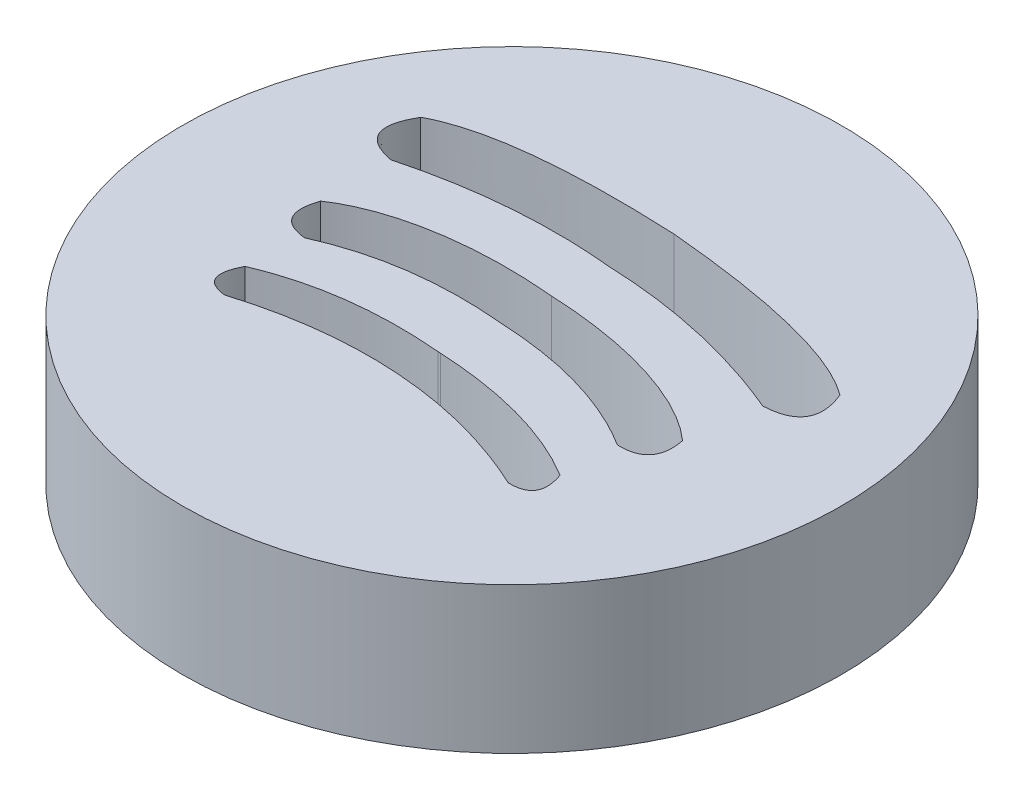
from build123d import *

# Parameters (mm, degrees)
SKETCH1_R           = 4.510832166
BOSS_EXTRUDE1_DEPTH = 2


with BuildPart() as part:
    # Sketch1 → Boss-Extrude1 (new body)
    with BuildSketch(Plane(origin=(0, 0, 0), x_dir=(1, 0, 0), z_dir=(0, 1, 0))):
        with Locations((4.847257792, 4.635414513)):
            Circle(SKETCH1_R)
        with BuildLine():
            Line((4.765839993, 3.704152946), (4.801053978, 3.701743172))
            add(Edge.make_bspline(
                [(4.801053978, 3.701743172), (6.14048774, 3.63517676), (7.067136471, 3.075228485)],
                knots=[0, 0, 0, 1, 1, 1], degree=2))
            add(Edge.make_bspline(
                [(7.067136471, 3.075228485), (7.229894904, 2.616221828), (6.804254242, 2.628959028)],
                knots=[0, 0, 0, 1, 1, 1], degree=2))
            add(Edge.make_bspline(
                [(6.804254242, 2.628959028), (5.8095543, 3.091031812), (4.77441326, 3.163396408)],
                knots=[0, 0, 0, 1, 1, 1], degree=2))
            Line((4.77441326, 3.163396408), (4.718895199, 3.167195635))
            add(Edge.make_bspline(
                [(2.635172404, 2.914258811), (3.683546068, 3.236519406), (4.718895199, 3.167195635)],
                knots=[0, 0, 0, 1, 1, 1], degree=2))
            add(Edge.make_bspline(
                [(2.43553462, 3.392179568), (2.211764545, 2.959623939), (2.635172404, 2.914258811)],
                knots=[0, 0, 0, 1, 1, 1], degree=2))
            add(Edge.make_bspline(
                [(4.765839993, 3.704152946), (3.429824714, 3.820673616), (2.43553462, 3.392179568)],
                knots=[0, 0, 0, 1, 1, 1], degree=2))
        make_face(mode=Mode.SUBTRACT)
        with BuildLine():
            Line((4.833097784, 4.473451505), (4.839222124, 4.473032403))
            add(Edge.make_bspline(
                [(7.101962805, 3.824170948), (6.157905723, 4.415694672), (4.839222124, 4.473032403)],
                knots=[0, 0, 0, 1, 1, 1], degree=2))
            add(Edge.make_bspline(
                [(7.496384151, 4.321712857), (7.596066747, 3.809653625), (7.101962805, 3.824170948)],
                knots=[0, 0, 0, 1, 1, 1], degree=2))
            add(Edge.make_bspline(
                [(4.881790421, 5.14003934), (6.140415114, 5.08430185), (7.038587479, 4.73304729), (7.496384151, 4.321712857)],
                knots=[0, 0, 0, 0, 1, 1, 1, 1], degree=3))
            add(Edge.make_bspline(
                [(4.881790421, 5.14003934), (3.627306072, 5.256279636), (2.689656518, 5.030654558), (2.180092864, 4.6855188)],
                knots=[0, 0, 0, 0, 1, 1, 1, 1], degree=3))
            add(Edge.make_bspline(
                [(2.180092864, 4.6855188), (2.011583443, 4.19181256), (2.503058846, 4.138884439)],
                knots=[0, 0, 0, 1, 1, 1], degree=2))
            add(Edge.make_bspline(
                [(2.503058846, 4.138884439), (3.518896422, 4.5962881), (4.833097784, 4.473451505)],
                knots=[0, 0, 0, 1, 1, 1], degree=2))
        make_face(mode=Mode.SUBTRACT)
        with BuildLine():
            add(Edge.make_bspline(
                [(4.98940547, 6.712616582), (2.708473933, 6.819328215), (1.870039434, 6.362412541)],
                knots=[0, 0, 0, 1, 1, 1], degree=2))
            add(Edge.make_bspline(
                [(1.870039434, 6.362412541), (1.529749193, 5.775598177), (2.172520926, 5.654605851)],
                knots=[0, 0, 0, 1, 1, 1], degree=2))
            add(Edge.make_bspline(
                [(2.172520926, 5.654605851), (3.539396322, 6.021113127), (4.93259631, 5.882465099)],
                knots=[0, 0, 0, 1, 1, 1], degree=2))
            add(Edge.make_bspline(
                [(7.635900953, 5.28073429), (6.331696023, 5.830029687), (4.93259631, 5.882465099)],
                knots=[0, 0, 0, 1, 1, 1], degree=2))
            add(Edge.make_bspline(
                [(8.031984733, 5.940736564), (8.289162951, 5.31303607), (7.635900953, 5.28073429)],
                knots=[0, 0, 0, 1, 1, 1], degree=2))
            add(Edge.make_bspline(
                [(4.98940547, 6.712616582), (7.263610448, 6.507609829), (8.031984733, 5.940736564)],
                knots=[0, 0, 0, 1, 1, 1], degree=2))
        make_face(mode=Mode.SUBTRACT)
    extrude(amount=BOSS_EXTRUDE1_DEPTH)


solid = part.part
